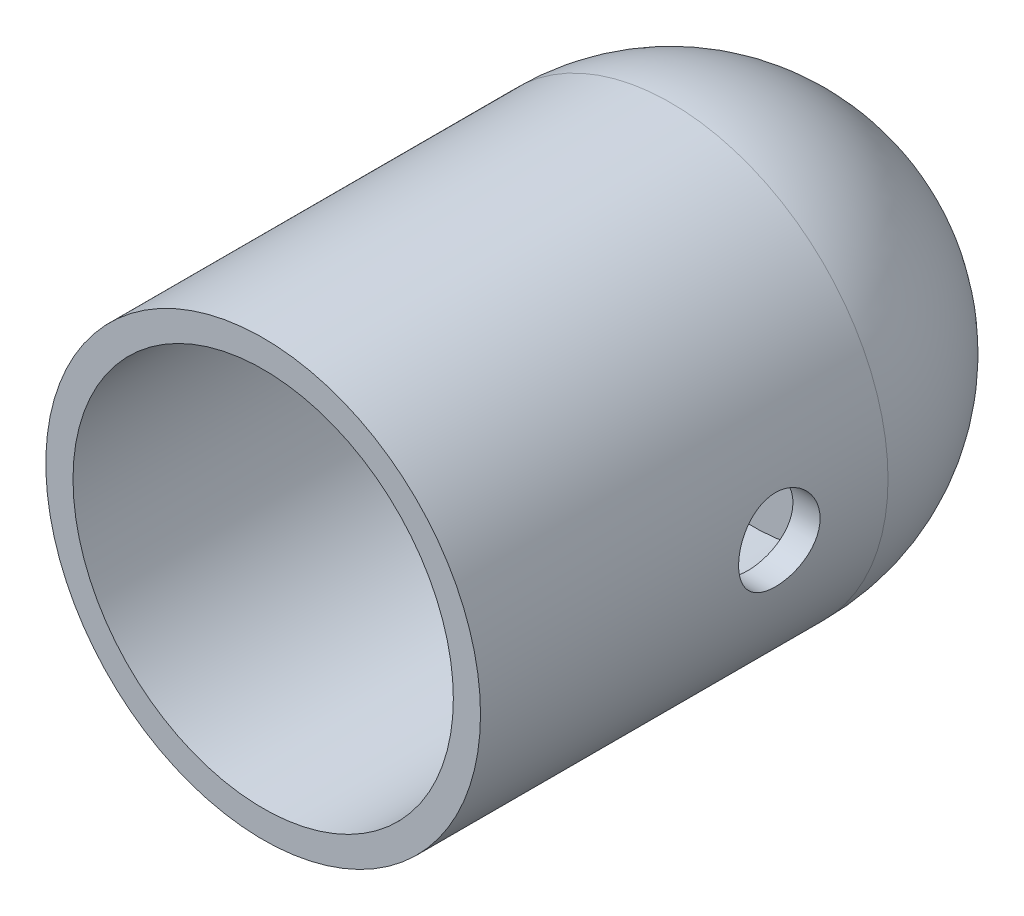
from build123d import *

# Parameters (mm, degrees)
SKETCH1_R               = 40
BOSS_EXTRUDE1_DEPTH     = 37.5
SKETCH3_R               = 7.5
CUT_EXTRUDE2_DEPTH      = 41
CUT_EXTRUDE2_DEPTH_BACK = 41
REVOLVE1_ANGLE          = 180
SKETCH2_R               = 35
CUT_EXTRUDE3_DEPTH      = 90


with BuildPart() as part:
    # Sketch1 → Boss-Extrude1 (new body, symmetric)
    with BuildSketch(Plane.XY):
        Circle(SKETCH1_R)
    extrude(amount=BOSS_EXTRUDE1_DEPTH, both=True)

    # Sketch3 → Cut-Extrude2 (cut, two sides)
    with BuildSketch(Plane(origin=(0, 0, 0), x_dir=(0, 0, -1), z_dir=(1, 0, 0))) as cut_extrude2_sk:
        with Locations((17.5, 0)):
            Circle(SKETCH3_R)
    extrude(amount=CUT_EXTRUDE2_DEPTH, mode=Mode.SUBTRACT)
    extrude(cut_extrude2_sk.sketch, amount=-CUT_EXTRUDE2_DEPTH_BACK, mode=Mode.SUBTRACT)

    # Sketch7 → Revolve1 (revolve)
    with BuildSketch(Plane(origin=(0, 0, -37.5), x_dir=(-1, 0, 0), z_dir=(0, 0, -1))):
        with BuildLine():
            Line((0, 40), (0, -40))
            ThreePointArc((0, -40), (-40, 0), (0, 40))
        make_face()
    revolve(axis=Axis((0, 40, -37.5), (0, 1, 0)), revolution_arc=REVOLVE1_ANGLE)

    # Sketch2 → Cut-Extrude3 (cut)
    with BuildSketch(Plane.XY.offset(37.5)):
        Circle(SKETCH2_R)
    extrude(amount=-CUT_EXTRUDE3_DEPTH, mode=Mode.SUBTRACT)


solid = part.part
